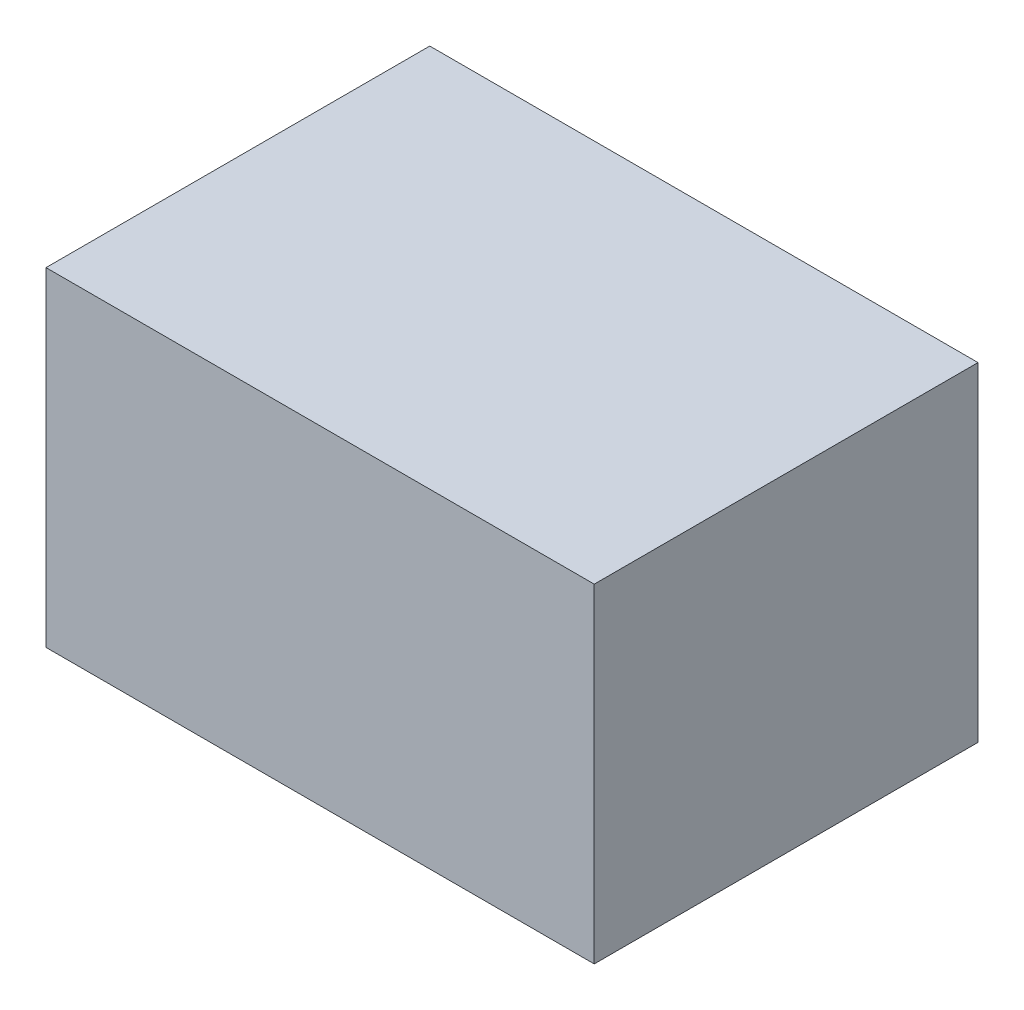
from build123d import *

# Parameters (mm, degrees)
SKETCH_1_W      = 7
SKETCH_1_H      = 6
EXTRUDE_1_DEPTH = 10


with BuildPart() as part:
    # Эскиз1 → Бобышка-Вытянуть1 (new body)
    with BuildSketch(Plane(origin=(0, 0, 0), x_dir=(0, 0, -1), z_dir=(1, 0, 0))):
        with Locations((3.5, 3)):
            Rectangle(SKETCH_1_W, SKETCH_1_H)
    extrude(amount=EXTRUDE_1_DEPTH)


solid = part.part
